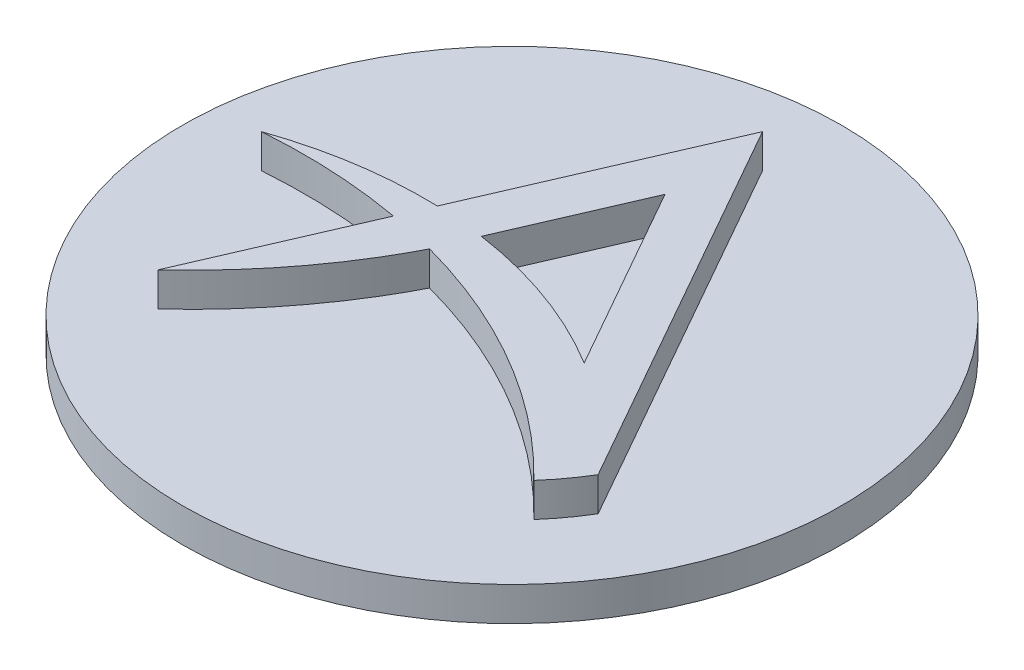
from build123d import *

# Parameters (mm, degrees)
SKETCH1_R           = 24.3
BOSS_EXTRUDE1_DEPTH = 2.5
BOSS_EXTRUDE3_DEPTH = 2.5


with BuildPart() as part:
    # Sketch1 → Boss-Extrude1 (new body)
    with BuildSketch(Plane(origin=(0, 0, 0), x_dir=(1, 0, 0), z_dir=(0, 1, 0))):
        Circle(SKETCH1_R)
    extrude(amount=BOSS_EXTRUDE1_DEPTH)

    # Sketch2 → Boss-Extrude3 (add)
    with BuildSketch(Plane(origin=(0, 2.5, 0), x_dir=(1, 0, 0), z_dir=(0, 1, 0))):
        with BuildLine():
            Line((-8.217088494, -0.523578651), (-13.461313625, -12.64466032))
            add(Edge.make_bspline(
                [(-13.461313625, -12.64466032), (-8.027902846, -7.603076106), (-4.786374516, -1.291203376)],
                knots=[0, 0, 0, 0.698779306, 0.698779306, 0.698779306], degree=2))
            ThreePointArc((-4.786374516, -1.291203376), (5.263745038, -5.505270352), (13.84122859, -12.227624065))
            ThreePointArc((13.84122859, -12.227624065), (14.904706404, -10.90615084), (15.842456672, -9.492679587))
            Line((15.842456672, -9.492679587), (0, 18.468741136))
            Line((0, 18.468741136), (-7.240743071, 1.733067912))
            ThreePointArc((-7.240743071, 1.733067912), (-12.934133358, 1.380884752), (-18.468741136, 0))
            ThreePointArc((-18.468741136, 0), (-13.32639579, 0.061652646), (-8.217088494, -0.523578651))
        make_face()
        with BuildLine():
            ThreePointArc((8.198670855, -2.878510194), (2.478425995, -0.121109089), (-3.681028203, 1.423425177))
            Line((-3.681028203, 1.423425177), (-0.630983691, 8.473053617))
            Line((-0.630983691, 8.473053617), (0.407335967, 10.872942458))
            Line((0.407335967, 10.872942458), (2.461520314, 7.247373901))
            Line((2.461520314, 7.247373901), (8.198670855, -2.878510194))
        make_face(mode=Mode.SUBTRACT)
    extrude(amount=BOSS_EXTRUDE3_DEPTH)


solid = part.part
